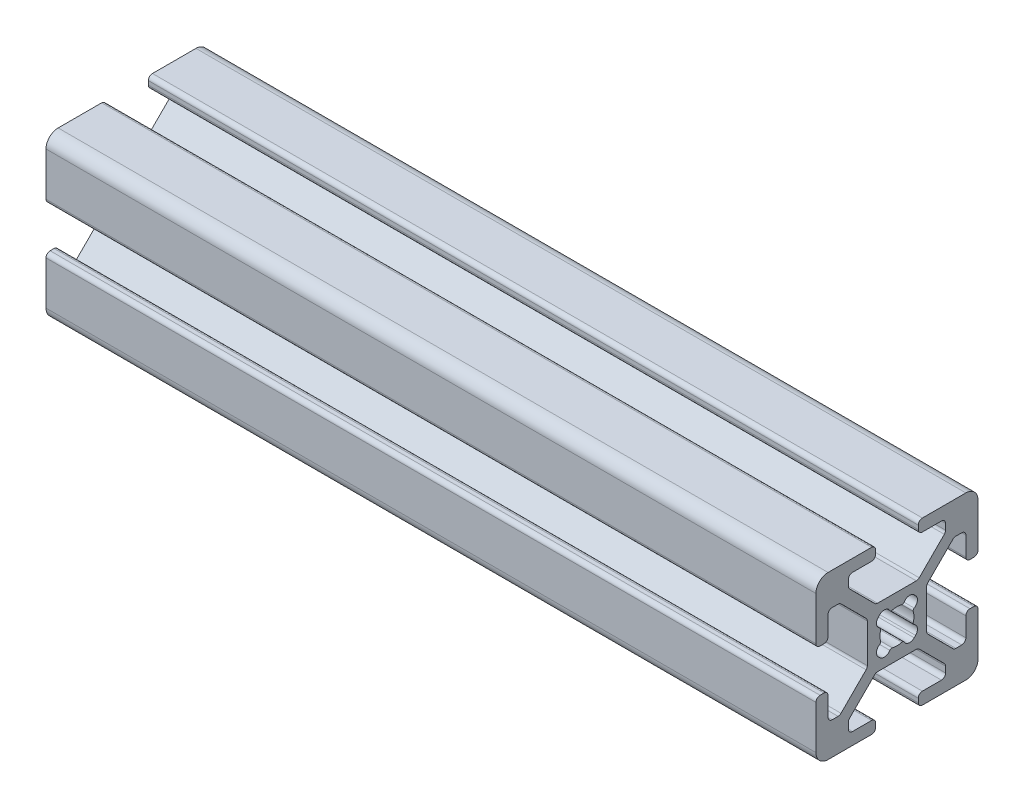
from build123d import *

# Parameters (mm, degrees)
F_20_SERIES_20_2020_1_DEPTH = 95


with BuildPart() as part:
    # Sketch11 → 20_series 20-2020(1) (new body)
    with BuildSketch(Plane(origin=(0, 0, 0), x_dir=(0, 0, -1), z_dir=(1, 0, 0))):
        with BuildLine():
            Line((9.0094, 2.6289), (9.492, 2.6289))
            ThreePointArc((9.492, 2.6289), (9.851210245, 2.777689755), (10, 3.1369))
            Line((10, 3.1369), (10, 8.5014))
            ThreePointArc((10, 8.5014), (9.561070222, 9.561070222), (8.5014, 10))
            Line((8.5014, 10), (3.1369, 10))
            ThreePointArc((3.1369, 10), (2.777689755, 9.851210245), (2.6289, 9.492))
            Line((2.6289, 9.492), (2.6289, 9.0094))
            ThreePointArc((2.6289, 9.0094), (2.777689755, 8.650189755), (3.1369, 8.5014))
            Line((3.1369, 8.5014), (5.4864, 8.5014))
            ThreePointArc((5.4864, 8.5014), (5.845610245, 8.352610245), (5.9944, 7.9934))
            Line((5.9944, 7.9934), (5.9944, 7.264490712))
            ThreePointArc((5.9944, 7.264490712), (5.955730803, 7.070087528), (5.845610245, 6.905280467))
            Line((5.845610245, 6.905280467), (2.747686782, 3.807357004))
            ThreePointArc((2.747686782, 3.807357004), (2.582879721, 3.697236446), (2.388476537, 3.658567249))
            Line((2.388476537, 3.658567249), (-2.388476537, 3.658567249))
            ThreePointArc((-2.388476537, 3.658567249), (-2.582879721, 3.697236446), (-2.747686782, 3.807357004))
            Line((-2.747686782, 3.807357004), (-5.845610245, 6.905280467))
            ThreePointArc((-5.845610245, 6.905280467), (-5.955730803, 7.070087528), (-5.9944, 7.264490712))
            Line((-5.9944, 7.264490712), (-5.9944, 7.9934))
            ThreePointArc((-5.9944, 7.9934), (-5.845610245, 8.352610245), (-5.4864, 8.5014))
            Line((-5.4864, 8.5014), (-3.1369, 8.5014))
            ThreePointArc((-3.1369, 8.5014), (-2.777689755, 8.650189755), (-2.6289, 9.0094))
            Line((-2.6289, 9.0094), (-2.6289, 9.492))
            ThreePointArc((-2.6289, 9.492), (-2.777689755, 9.851210245), (-3.1369, 10))
            Line((-3.1369, 10), (-8.5014, 10))
            ThreePointArc((-8.5014, 10), (-9.561070222, 9.561070222), (-10, 8.5014))
            Line((-10, 8.5014), (-10, 3.1369))
            ThreePointArc((-10, 3.1369), (-9.851210245, 2.777689755), (-9.492, 2.6289))
            Line((-9.492, 2.6289), (-9.0094, 2.6289))
            ThreePointArc((-9.0094, 2.6289), (-8.650189755, 2.777689755), (-8.5014, 3.1369))
            Line((-8.5014, 3.1369), (-8.5014, 5.4864))
            ThreePointArc((-8.5014, 5.4864), (-8.352610245, 5.845610245), (-7.9934, 5.9944))
            Line((-7.9934, 5.9944), (-7.264490712, 5.9944))
            ThreePointArc((-7.264490712, 5.9944), (-7.070087528, 5.955730803), (-6.905280467, 5.845610245))
            Line((-6.905280467, 5.845610245), (-3.807357004, 2.747686782))
            ThreePointArc((-3.807357004, 2.747686782), (-3.697236446, 2.582879721), (-3.658567249, 2.388476537))
            Line((-3.658567249, 2.388476537), (-3.658567249, -2.388476537))
            ThreePointArc((-3.658567249, -2.388476537), (-3.697236446, -2.582879721), (-3.807357004, -2.747686782))
            Line((-3.807357004, -2.747686782), (-6.905280467, -5.845610245))
            ThreePointArc((-6.905280467, -5.845610245), (-7.070087528, -5.955730803), (-7.264490712, -5.9944))
            Line((-7.264490712, -5.9944), (-7.9934, -5.9944))
            ThreePointArc((-7.9934, -5.9944), (-8.352610245, -5.845610245), (-8.5014, -5.4864))
            Line((-8.5014, -5.4864), (-8.5014, -3.1369))
            ThreePointArc((-8.5014, -3.1369), (-8.650189755, -2.777689755), (-9.0094, -2.6289))
            Line((-9.0094, -2.6289), (-9.492, -2.6289))
            ThreePointArc((-9.492, -2.6289), (-9.851210245, -2.777689755), (-10, -3.1369))
            Line((-10, -3.1369), (-10, -8.5014))
            ThreePointArc((-10, -8.5014), (-9.561070222, -9.561070222), (-8.5014, -10))
            Line((-8.5014, -10), (-3.1369, -10))
            ThreePointArc((-3.1369, -10), (-2.777689755, -9.851210245), (-2.6289, -9.492))
            Line((-2.6289, -9.492), (-2.6289, -9.0094))
            ThreePointArc((-2.6289, -9.0094), (-2.777689755, -8.650189755), (-3.1369, -8.5014))
            Line((-3.1369, -8.5014), (-5.4864, -8.5014))
            ThreePointArc((-5.4864, -8.5014), (-5.845610245, -8.352610245), (-5.9944, -7.9934))
            Line((-5.9944, -7.9934), (-5.9944, -7.264490712))
            ThreePointArc((-5.9944, -7.264490712), (-5.955730803, -7.070087528), (-5.845610245, -6.905280467))
            Line((-5.845610245, -6.905280467), (-2.747686782, -3.807357004))
            ThreePointArc((-2.747686782, -3.807357004), (-2.582879721, -3.697236446), (-2.388476537, -3.658567249))
            Line((-2.388476537, -3.658567249), (2.388476537, -3.658567249))
            ThreePointArc((2.388476537, -3.658567249), (2.582879721, -3.697236446), (2.747686782, -3.807357004))
            Line((2.747686782, -3.807357004), (5.845610245, -6.905280467))
            ThreePointArc((5.845610245, -6.905280467), (5.955730803, -7.070087528), (5.9944, -7.264490712))
            Line((5.9944, -7.264490712), (5.9944, -7.9934))
            ThreePointArc((5.9944, -7.9934), (5.845610245, -8.352610245), (5.4864, -8.5014))
            Line((5.4864, -8.5014), (3.1369, -8.5014))
            ThreePointArc((3.1369, -8.5014), (2.777689755, -8.650189755), (2.6289, -9.0094))
            Line((2.6289, -9.0094), (2.6289, -9.492))
            ThreePointArc((2.6289, -9.492), (2.777689755, -9.851210245), (3.1369, -10))
            Line((3.1369, -10), (8.5014, -10))
            ThreePointArc((8.5014, -10), (9.561070222, -9.561070222), (10, -8.5014))
            Line((10, -8.5014), (10, -3.1369))
            ThreePointArc((10, -3.1369), (9.851210245, -2.777689755), (9.492, -2.6289))
            Line((9.492, -2.6289), (9.0094, -2.6289))
            ThreePointArc((9.0094, -2.6289), (8.650189755, -2.777689755), (8.5014, -3.1369))
            Line((8.5014, -3.1369), (8.5014, -5.4864))
            ThreePointArc((8.5014, -5.4864), (8.352610245, -5.845610245), (7.9934, -5.9944))
            Line((7.9934, -5.9944), (7.264490712, -5.9944))
            ThreePointArc((7.264490712, -5.9944), (7.070087528, -5.955730803), (6.905280467, -5.845610245))
            Line((6.905280467, -5.845610245), (3.807357004, -2.747686782))
            ThreePointArc((3.807357004, -2.747686782), (3.697236446, -2.582879721), (3.658567249, -2.388476537))
            Line((3.658567249, -2.388476537), (3.658567249, 2.388476537))
            ThreePointArc((3.658567249, 2.388476537), (3.697236446, 2.582879721), (3.807357004, 2.747686782))
            Line((3.807357004, 2.747686782), (6.905280467, 5.845610245))
            ThreePointArc((6.905280467, 5.845610245), (7.070087528, 5.955730803), (7.264490712, 5.9944))
            Line((7.264490712, 5.9944), (7.9934, 5.9944))
            ThreePointArc((7.9934, 5.9944), (8.352610245, 5.845610245), (8.5014, 5.4864))
            Line((8.5014, 5.4864), (8.5014, 3.1369))
            ThreePointArc((8.5014, 3.1369), (8.650189755, 2.777689755), (9.0094, 2.6289))
        make_face()
        with BuildLine():
            Line((-2.296558466, 2.121727546), (-2.121727546, 2.296558466))
            ThreePointArc((-2.121727546, 2.296558466), (-1.459775814, 2.520126613), (-0.880635441, 2.129282347))
            ThreePointArc((-0.880635441, 2.129282347), (-0.755121693, 2.019456424), (-0.588548999, 2.011151493))
            ThreePointArc((-0.588548999, 2.011151493), (0, 2.0955), (0.588548999, 2.011151493))
            ThreePointArc((0.588548999, 2.011151493), (0.755121693, 2.019456424), (0.880635441, 2.129282347))
            ThreePointArc((0.880635441, 2.129282347), (1.459775814, 2.520126613), (2.121727546, 2.296558466))
            Line((2.121727546, 2.296558466), (2.296558466, 2.121727546))
            ThreePointArc((2.296558466, 2.121727546), (2.520126613, 1.459775814), (2.129282347, 0.880635441))
            ThreePointArc((2.129282347, 0.880635441), (2.019456424, 0.755121693), (2.011151493, 0.588548999))
            ThreePointArc((2.011151493, 0.588548999), (2.0955, 0), (2.011151493, -0.588548999))
            ThreePointArc((2.011151493, -0.588548999), (2.019456424, -0.755121693), (2.129282347, -0.880635441))
            ThreePointArc((2.129282347, -0.880635441), (2.520126613, -1.459775814), (2.296558466, -2.121727546))
            Line((2.296558466, -2.121727546), (2.121727546, -2.296558466))
            ThreePointArc((2.121727546, -2.296558466), (1.459775814, -2.520126613), (0.880635441, -2.129282347))
            ThreePointArc((0.880635441, -2.129282347), (0.755121693, -2.019456424), (0.588548999, -2.011151493))
            ThreePointArc((0.588548999, -2.011151493), (0, -2.0955), (-0.588548999, -2.011151493))
            ThreePointArc((-0.588548999, -2.011151493), (-0.755121693, -2.019456424), (-0.880635441, -2.129282347))
            ThreePointArc((-0.880635441, -2.129282347), (-1.459775814, -2.520126613), (-2.121727546, -2.296558466))
            Line((-2.121727546, -2.296558466), (-2.296558466, -2.121727546))
            ThreePointArc((-2.296558466, -2.121727546), (-2.520126613, -1.459775814), (-2.129282347, -0.880635441))
            ThreePointArc((-2.129282347, -0.880635441), (-2.019456424, -0.755121693), (-2.011151493, -0.588548999))
            ThreePointArc((-2.011151493, -0.588548999), (-2.0955, 0), (-2.011151493, 0.588548999))
            ThreePointArc((-2.011151493, 0.588548999), (-2.019456424, 0.755121693), (-2.129282347, 0.880635441))
            ThreePointArc((-2.129282347, 0.880635441), (-2.520126613, 1.459775814), (-2.296558466, 2.121727546))
        make_face(mode=Mode.SUBTRACT)
    extrude(amount=F_20_SERIES_20_2020_1_DEPTH)


solid = part.part
